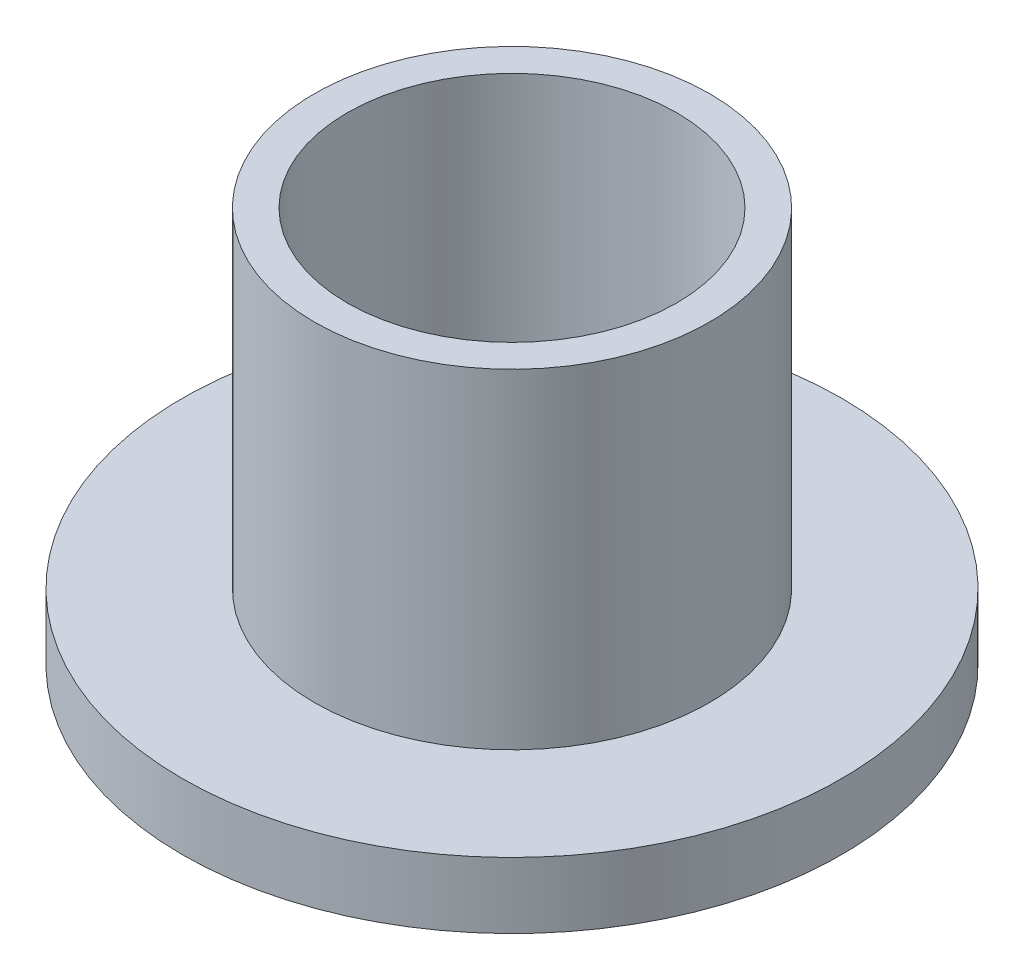
from build123d import *

# Parameters (mm, degrees)
SKETCH1_R           = 10
BOSS_EXTRUDE1_DEPTH = 2
SKETCH2_R           = 6
BOSS_EXTRUDE2_DEPTH = 10
SKETCH3_R           = 5
CUT_EXTRUDE2_DEPTH  = 27


with BuildPart() as part:
    # Sketch1 → Boss-Extrude1 (new body)
    with BuildSketch(Plane(origin=(0, 0, 0), x_dir=(1, 0, 0), z_dir=(0, 1, 0))):
        Circle(SKETCH1_R)
    extrude(amount=BOSS_EXTRUDE1_DEPTH)

    # Sketch2 → Boss-Extrude2 (add)
    with BuildSketch(Plane(origin=(0, 2, 0), x_dir=(1, 0, 0), z_dir=(0, 1, 0))):
        Circle(SKETCH2_R)
    extrude(amount=BOSS_EXTRUDE2_DEPTH)

    # Sketch3 → Cut-Extrude2 (cut)
    with BuildSketch(Plane(origin=(0, 12, 0), x_dir=(1, 0, 0), z_dir=(0, 1, 0))):
        Circle(SKETCH3_R)
    extrude(amount=-CUT_EXTRUDE2_DEPTH, mode=Mode.SUBTRACT)


solid = part.part
